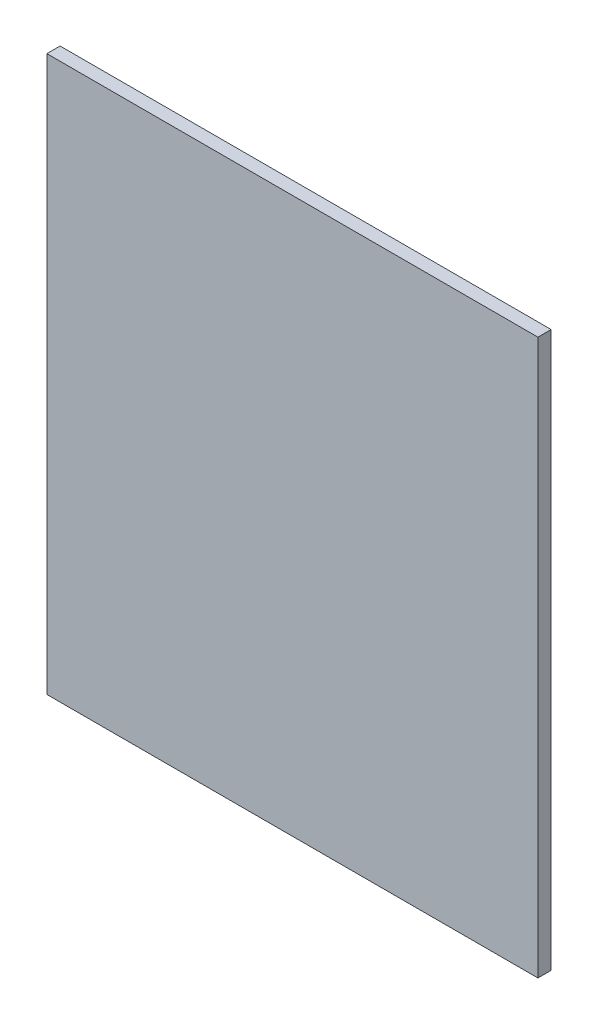
from build123d import *

# Parameters (mm, degrees)
SKETCH4_W           = 235.957625426
SKETCH4_H           = 266.673613736
BOSS_EXTRUDE1_DEPTH = 3.175
SCALE1_SCALE        = 0.8


with BuildPart() as part:
    # Sketch4 → Boss-Extrude1 (new body, symmetric)
    with BuildSketch(Plane.XY):
        with Locations((-117.978812713, 133.336806868)):
            Rectangle(SKETCH4_W, SKETCH4_H)
    extrude(amount=BOSS_EXTRUDE1_DEPTH, both=True)


with BuildPart() as part_1:
    # Scale1: scaled about (0, 0, 0)
    add(part.part.scale(SCALE1_SCALE))


solid = part_1.part
